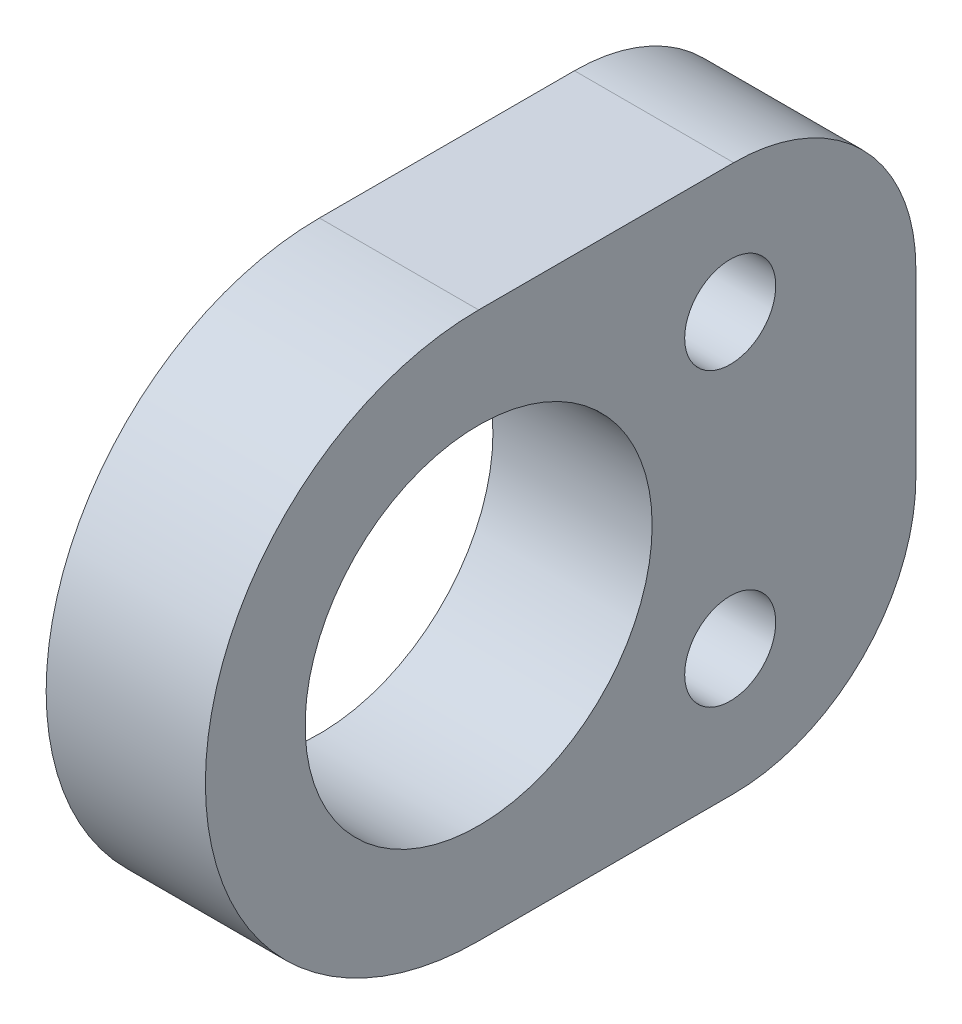
from build123d import *

# Parameters (mm, degrees)
SKETCH1_R             = 4.7625
BOSS_EXTRUDE1_DEPTH   = 4.37
FILLET1_R             = 5
M3X0_5_TAPPED_HOLE1_D = 2.5


with BuildPart() as part:
    # Sketch1 → Boss-Extrude1 (new body)
    with BuildSketch(Plane(origin=(0, 0, 0), x_dir=(0, 0, -1), z_dir=(1, 0, 0))):
        with BuildLine():
            Line((0, 7.5), (12, 7.5))
            Line((12, 7.5), (12, -7.5))
            Line((12, -7.5), (0, -7.5))
            ThreePointArc((0, -7.5), (-7.5, 0), (0, 7.5))
        make_face()
        Circle(SKETCH1_R, mode=Mode.SUBTRACT)
    extrude(amount=BOSS_EXTRUDE1_DEPTH)

    # Fillet1
    fillet1_edges = [part.edges().sort_by_distance(p)[0] for p in [
        (2.185, -7.5, -12),
        (2.185, 7.5, -12),
    ]]
    fillet(fillet1_edges, radius=FILLET1_R)

    # M3x0.5 Tapped Hole1 (through all)
    with Locations(Plane.ZY):
        with Locations((-6.905099565, 4), (-6.905099565, -4)):
            Hole(M3X0_5_TAPPED_HOLE1_D / 2)


solid = part.part
